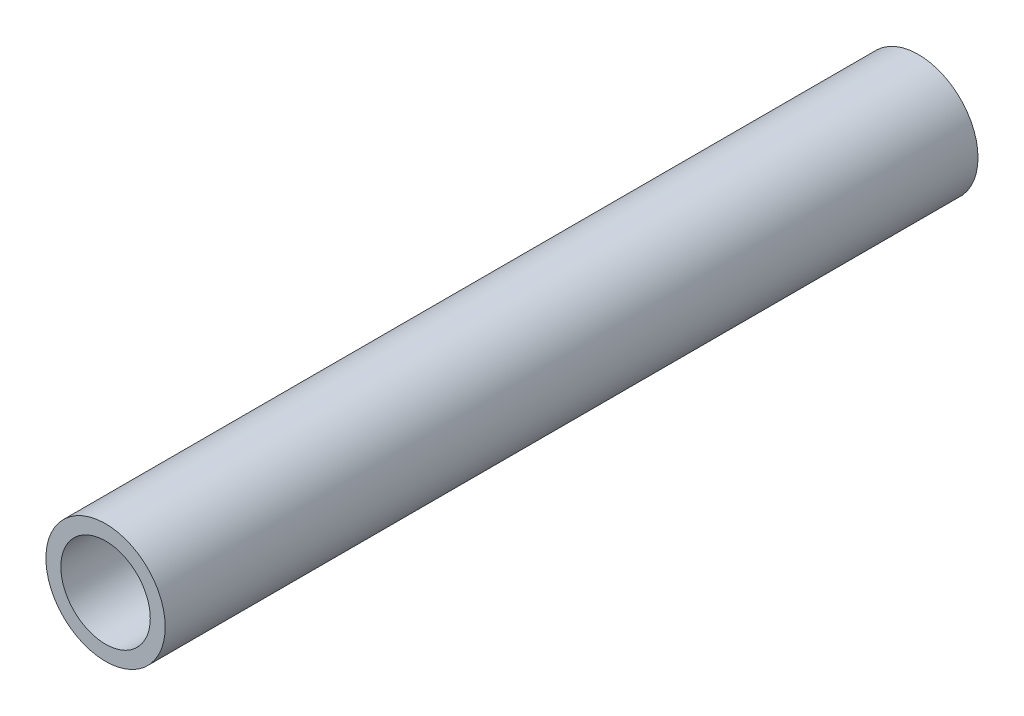
from build123d import *

# Parameters (mm, degrees)
SKETCH1_R           = 4
BOSS_EXTRUDE1_DEPTH = 54.5
SKETCH2_R           = 3
CUT_EXTRUDE1_DEPTH  = 20.5


with BuildPart() as part:
    # Sketch1 → Boss-Extrude1 (new body)
    with BuildSketch(Plane.XY):
        Circle(SKETCH1_R)
    extrude(amount=BOSS_EXTRUDE1_DEPTH)

    # Sketch2 → Cut-Extrude1 (cut)
    with BuildSketch(Plane.XY.offset(54.5)):
        Circle(SKETCH2_R)
    extrude(amount=-CUT_EXTRUDE1_DEPTH, mode=Mode.SUBTRACT)


solid = part.part
